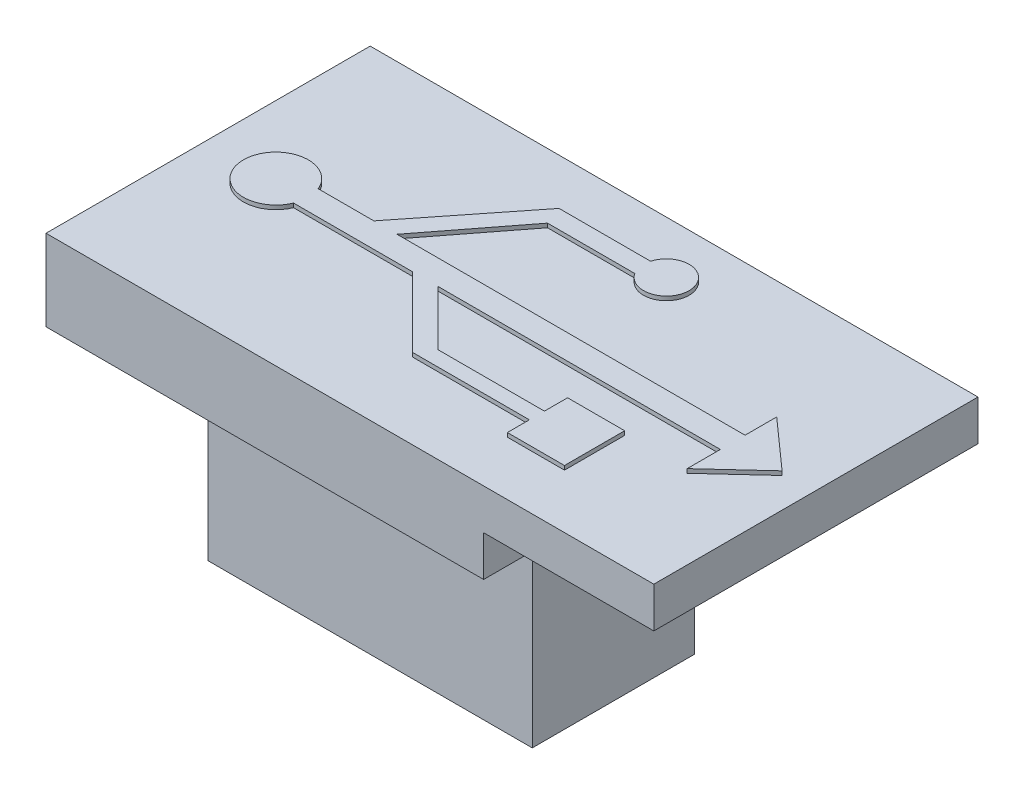
from build123d import *

# Parameters (mm, degrees)
ESQUISSE2_W      = 15
ESQUISSE2_H      = 8
EXTRUSION1_DEPTH = 1
ESQUISSE3_W      = 10.8
ESQUISSE3_H      = 8
EXTRUSION2_DEPTH = 1
ESQUISSE4_W      = 8
ESQUISSE4_H      = 4
EXTRUSION3_DEPTH = 5
ESQUISSE5_W      = 0.476113498
ESQUISSE5_H      = 0.8
EXTRUSION4_DEPTH = 3
EXTRUSION5_DEPTH = 0.1


with BuildPart() as part:
    # Esquisse2 → Extrusion1 (new body)
    with BuildSketch(Plane(origin=(0, 0, 0), x_dir=(1, 0, 0), z_dir=(0, 1, 0))):
        with Locations((7.5, 4)):
            Rectangle(ESQUISSE2_W, ESQUISSE2_H)
    extrude(amount=EXTRUSION1_DEPTH)

    # Esquisse3 → Extrusion2 (add)
    with BuildSketch(Plane.XZ):
        with Locations((5.4, -4)):
            Rectangle(ESQUISSE3_W, ESQUISSE3_H)
    extrude(amount=EXTRUSION2_DEPTH)

    # Esquisse4 → Extrusion3 (add)
    with BuildSketch(Plane.XZ.offset(1)):
        with Locations((6, -4)):
            Rectangle(ESQUISSE4_W, ESQUISSE4_H)
    extrude(amount=EXTRUSION3_DEPTH)

    # Esquisse5 → Extrusion4 (cut)
    with BuildSketch(Plane.XZ.offset(6)):
        with Locations((2.786488869, -2.7)):
            Rectangle(ESQUISSE5_W, ESQUISSE5_H)
        with Locations((4.886488869, -2.7)):
            Rectangle(ESQUISSE5_W, ESQUISSE5_H)
        with Locations((6.986488869, -2.7)):
            Rectangle(ESQUISSE5_W, ESQUISSE5_H)
        with Locations((9.086488869, -2.7)):
            Rectangle(ESQUISSE5_W, ESQUISSE5_H)
        with Locations((2.786488869, -5.2)):
            Rectangle(ESQUISSE5_W, ESQUISSE5_H)
        with Locations((4.886488869, -5.2)):
            Rectangle(ESQUISSE5_W, ESQUISSE5_H)
        with Locations((6.986488869, -5.2)):
            Rectangle(ESQUISSE5_W, ESQUISSE5_H)
        with Locations((9.086488869, -5.2)):
            Rectangle(ESQUISSE5_W, ESQUISSE5_H)
    extrude(amount=-EXTRUSION4_DEPTH, mode=Mode.SUBTRACT)

    # Esquisse6 → Extrusion5 (add)
    with BuildSketch(Plane(origin=(0, 1, 0), x_dir=(1, 0, 0), z_dir=(0, 1, 0))):
        with BuildLine():
            Line((13.041973618, 4.209489939), (13.041973618, 4.990316076))
            Line((13.041973618, 4.990316076), (14.260824173, 3.9047773))
            Line((14.260824173, 3.9047773), (13.041973618, 2.781149445))
            Line((13.041973618, 2.781149445), (13.041973618, 3.600064662))
            Line((13.041973618, 3.600064662), (6.071672006, 3.600064662))
            Line((6.071672006, 3.600064662), (7.42383434, 2.247902327))
            Line((7.42383434, 2.247902327), (10.05198085, 2.247902327))
            Line((10.05198085, 2.247902327), (10.05198085, 2.819238525))
            Line((10.05198085, 2.819238525), (11.461276804, 2.819238525))
            Line((11.461276804, 2.819238525), (11.461276804, 1.333764411))
            Line((11.461276804, 1.333764411), (10.05198085, 1.333764411))
            Line((10.05198085, 1.333764411), (10.05198085, 1.876533798))
            Line((10.05198085, 1.876533798), (7.166733051, 1.876533798))
            Line((7.166733051, 1.876533798), (5.443202188, 3.600064662))
            Line((5.443202188, 3.600064662), (2.508387178, 3.600064662))
            ThreePointArc((2.508387178, 3.600064662), (0.966602505, 3.9047773), (2.508387178, 4.209489939))
            Line((2.508387178, 4.209489939), (3.881549914, 4.209489939))
            Line((3.881549914, 4.209489939), (5.900271146, 6.761458289))
            Line((5.900271146, 6.761458289), (8.158136089, 6.761458289))
            ThreePointArc((8.158136089, 6.761458289), (9.25628218, 6.692651293), (8.226761957, 6.304389331))
            Line((8.226761957, 6.304389331), (6.071672006, 6.304389331))
            Line((6.071672006, 6.304389331), (4.452886112, 4.209489939))
            Line((4.452886112, 4.209489939), (13.041973618, 4.209489939))
        make_face()
    extrude(amount=EXTRUSION5_DEPTH)


solid = part.part
